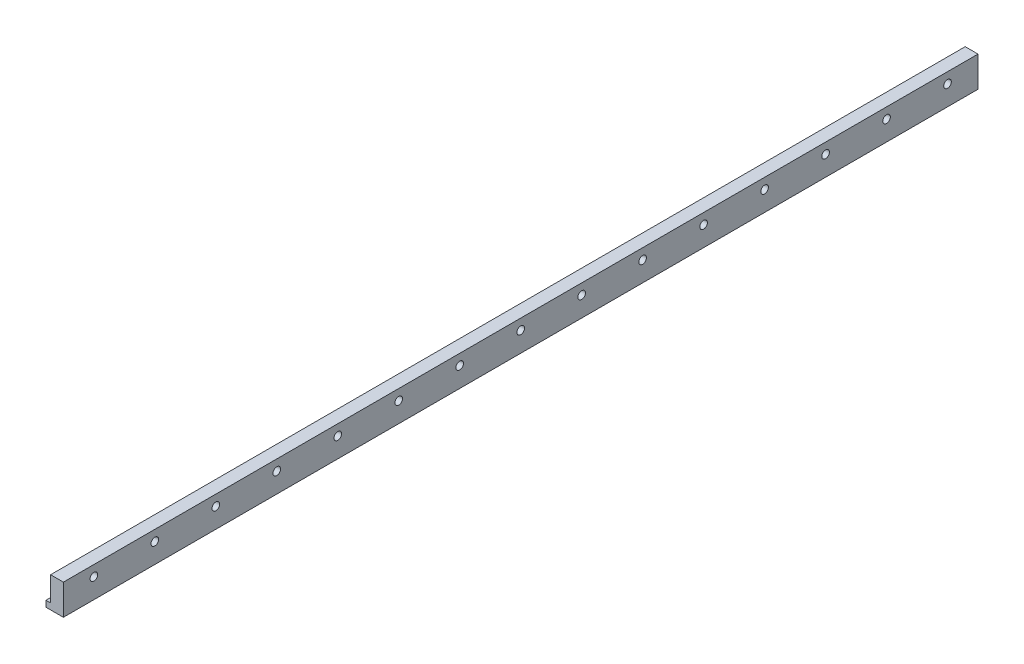
from build123d import *

# Parameters (mm, degrees)
SKETCH1_W             = 4.2
SKETCH1_H             = 9.05
BOSS_EXTRUDE1_DEPTH   = 150
M3X0_5_TAPPED_HOLE1_D = 2.5
LPATTERN1_COUNT       = 15
LPATTERN1_PITCH       = 20
SKETCH7_W             = 5.7
SKETCH7_H             = 2
BOSS_EXTRUDE3_DEPTH   = 300
SKETCH9_W             = 5.7
SKETCH9_H             = 3.05
CUT_EXTRUDE2_DEPTH    = 301


with BuildPart() as part:
    # Sketch1 → Boss-Extrude1 (new body, symmetric)
    with BuildSketch(Plane.XY):
        Rectangle(SKETCH1_W, SKETCH1_H)
    extrude(amount=BOSS_EXTRUDE1_DEPTH, both=True)

    # M3x0.5 Tapped Hole1 (through all)
    with Locations(Plane.ZY.offset(2.1)):
        with Locations((-140, 0)):
            m3x0_5_tapped_hole1 = Hole(M3X0_5_TAPPED_HOLE1_D / 2)

    # LPattern1: M3x0.5 Tapped Hole1 ×15
    with Locations(*[(0, 0, i * LPATTERN1_PITCH) for i in range(1, LPATTERN1_COUNT)]):
        add(m3x0_5_tapped_hole1, mode=Mode.SUBTRACT)

    # Sketch7 → Boss-Extrude3 (add)
    with BuildSketch(Plane.XY.offset(150)):
        with Locations((-0.75, 5.525)):
            Rectangle(SKETCH7_W, SKETCH7_H)
        with Locations((-0.75, -5.525)):
            Rectangle(SKETCH7_W, SKETCH7_H)
    extrude(amount=-BOSS_EXTRUDE3_DEPTH)

    # Sketch9 → Cut-Extrude2 (cut, through all)
    with BuildSketch(Plane.XY.offset(150)):
        with Locations((-0.75, 5)):
            Rectangle(SKETCH9_W, SKETCH9_H)
    extrude(amount=-CUT_EXTRUDE2_DEPTH, mode=Mode.SUBTRACT)


solid = part.part
